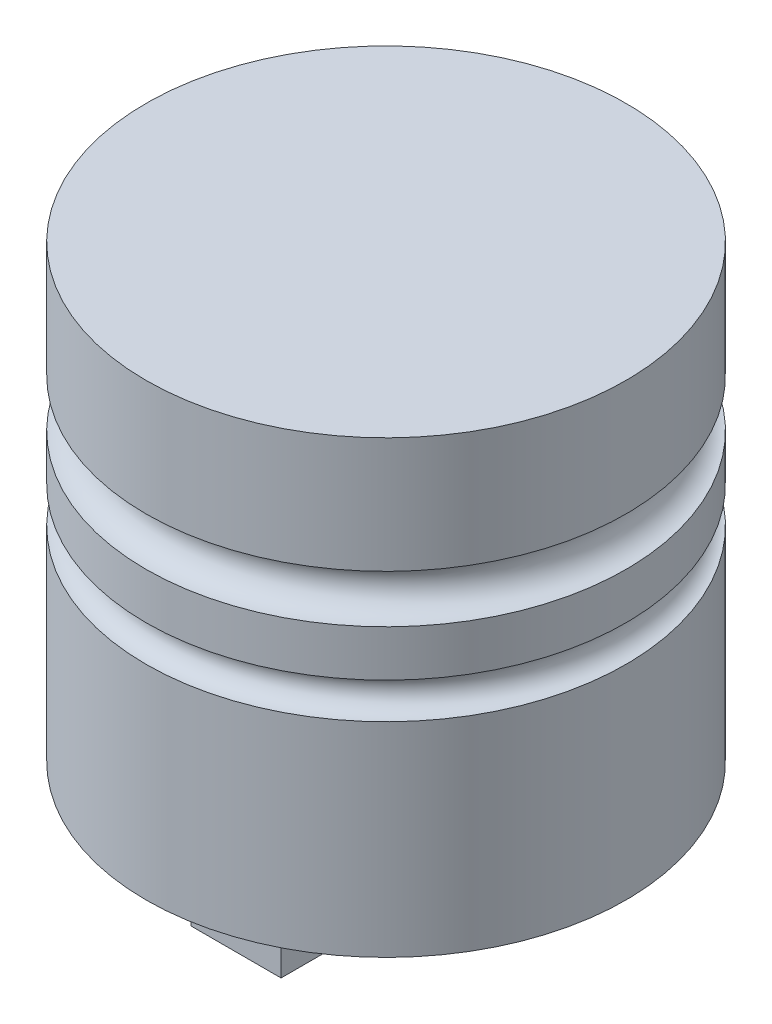
from build123d import *

# Parameters (mm, degrees)
SKETCH3_W           = 30
SKETCH3_H           = 30
BOSS_EXTRUDE1_DEPTH = 30
SKETCH4_R           = 10
BOSS_EXTRUDE2_DEPTH = 40


with BuildPart() as part:
    # Sketch1 → Revolve1 (revolve)
    with BuildSketch(Plane.XY):
        with BuildLine():
            Line((0, 74.602122016), (0, -75.397877984))
            Line((0, -75.397877984), (80, -75.397877984))
            Line((80, -75.397877984), (80, -7.360742706))
            ThreePointArc((80, -7.360742706), (74, -1.360742706), (80, 4.639257294))
            Line((80, 4.639257294), (80, 20.050397878))
            ThreePointArc((80, 20.050397878), (72, 28.050397878), (80, 36.050397878))
            Line((80, 36.050397878), (80, 74.602122016))
            Line((80, 74.602122016), (0, 74.602122016))
        make_face()
    revolve(axis=Axis((0, 74.602122016, 0), (0, -1, 0)))

    # Sketch3 → Boss-Extrude1 (add)
    with BuildSketch(Plane.XZ.offset(75.397877984)):
        with Locations((0, -35)):
            Rectangle(SKETCH3_W, SKETCH3_H)
        with Locations((0, 35)):
            Rectangle(SKETCH3_W, SKETCH3_H)
    extrude(amount=BOSS_EXTRUDE1_DEPTH)

    # Sketch4 → Boss-Extrude2 (add)
    with BuildSketch(Plane(origin=(0, 0, 20), x_dir=(-1, 0, 0), z_dir=(0, 0, -1))):
        with Locations((0, -90.397877984)):
            Circle(SKETCH4_R)
    extrude(amount=BOSS_EXTRUDE2_DEPTH)


solid = part.part
